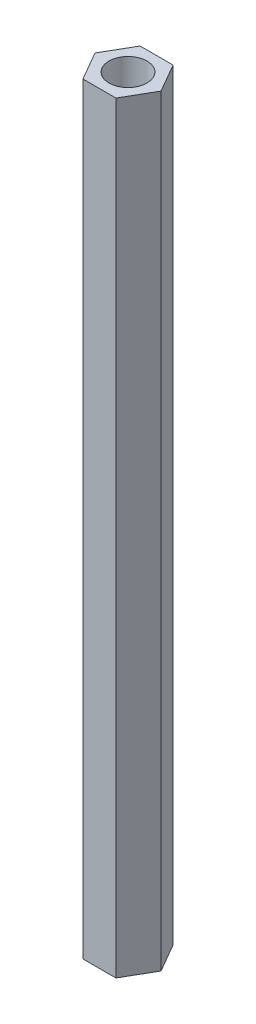
from build123d import *

# Parameters (mm, degrees)
SKETCH_1_R      = 2
EXTRUDE_1_DEPTH = 80


with BuildPart() as part:
    # 草图1 → 凸台-拉伸1 (new body)
    with BuildSketch(Plane(origin=(0, 0, 0), x_dir=(1, 0, 0), z_dir=(0, 1, 0))):
        Polygon((1.732050808, 3), (-1.732050808, 3), (-3.464101615, 0), (-1.732050808, -3), (1.732050808, -3), (3.464101615, 0), align=None)
        Circle(SKETCH_1_R, mode=Mode.SUBTRACT)
    extrude(amount=EXTRUDE_1_DEPTH)


solid = part.part
